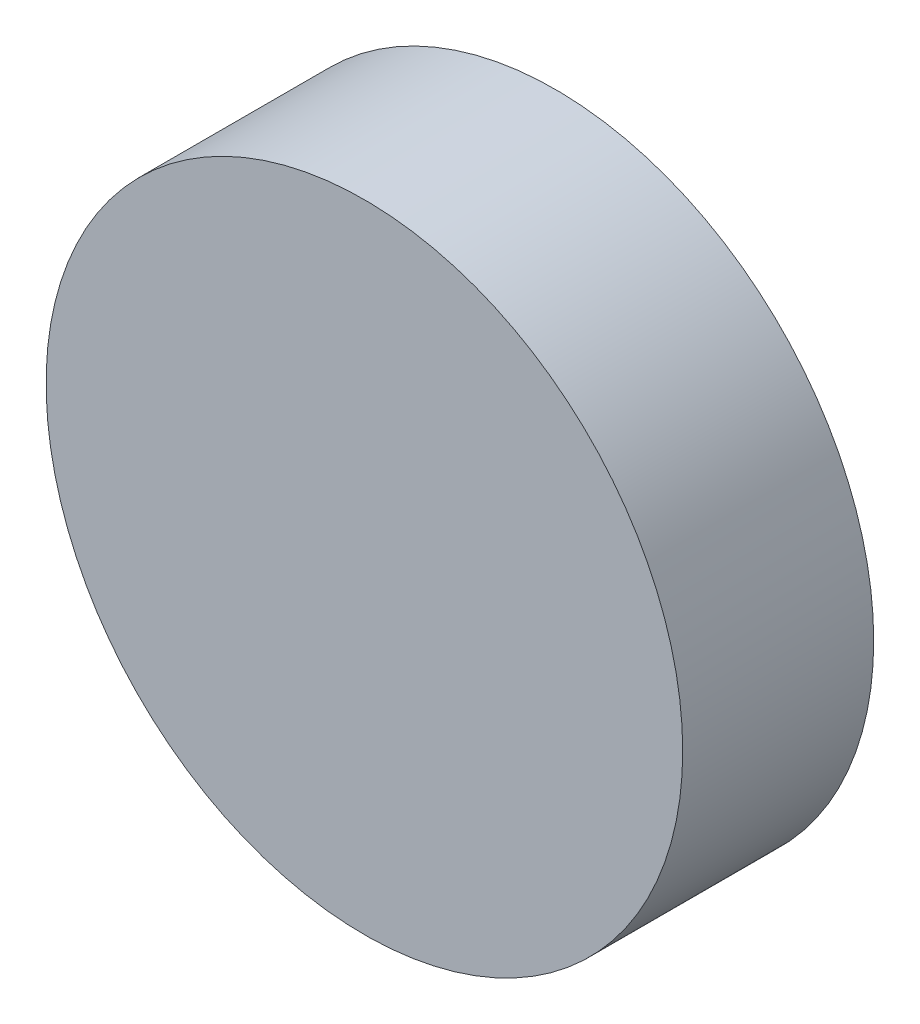
from build123d import *

# Parameters (mm, degrees)
SKETCH1_R           = 10
BOSS_EXTRUDE1_DEPTH = 6


with BuildPart() as part:
    # Sketch1 → Boss-Extrude1 (new body)
    with BuildSketch(Plane.XY):
        Circle(SKETCH1_R)
    extrude(amount=BOSS_EXTRUDE1_DEPTH)


solid = part.part
